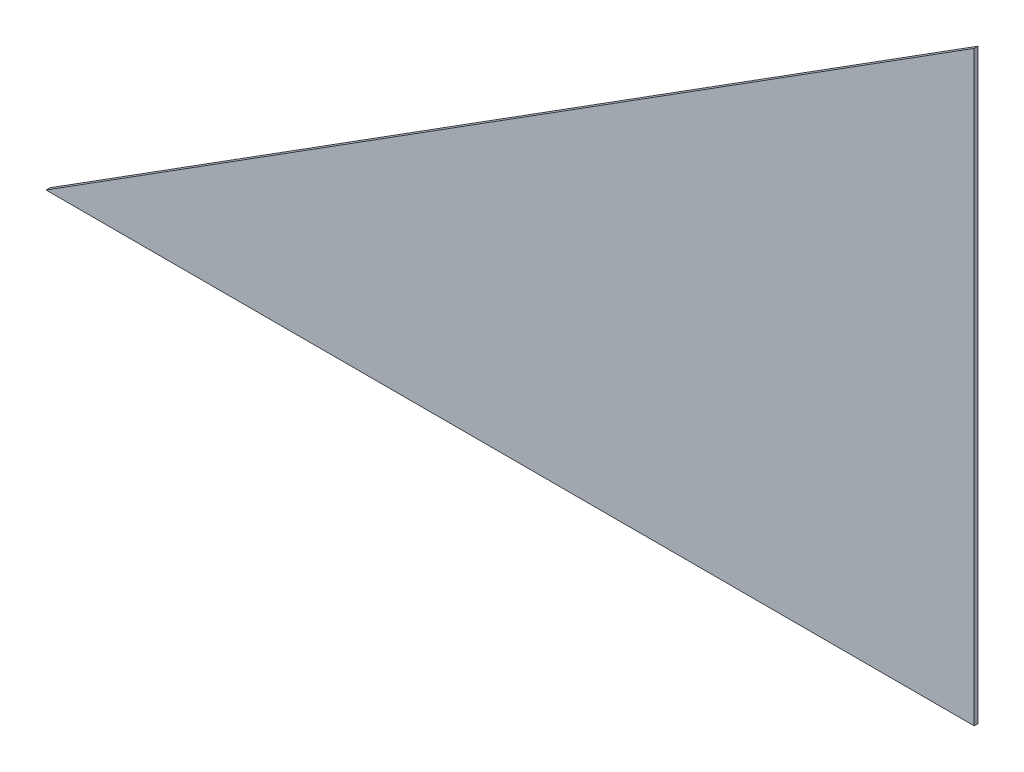
from build123d import *

# Parameters (mm, degrees)
BOSS_EXTRUDE1_DEPTH = 2.54


with BuildPart() as part:
    # Sketch1 → Boss-Extrude1 (new body)
    with BuildSketch(Plane(origin=(0, 0, 1121.25455637), x_dir=(-1, 0, 0), z_dir=(0, 0, -1))):
        Polygon((86.167457674, 1821.517106037), (-523.432542326, 1821.517106037), (-523.432542326, 2206.854377562), align=None)
    extrude(amount=BOSS_EXTRUDE1_DEPTH)


solid = part.part
